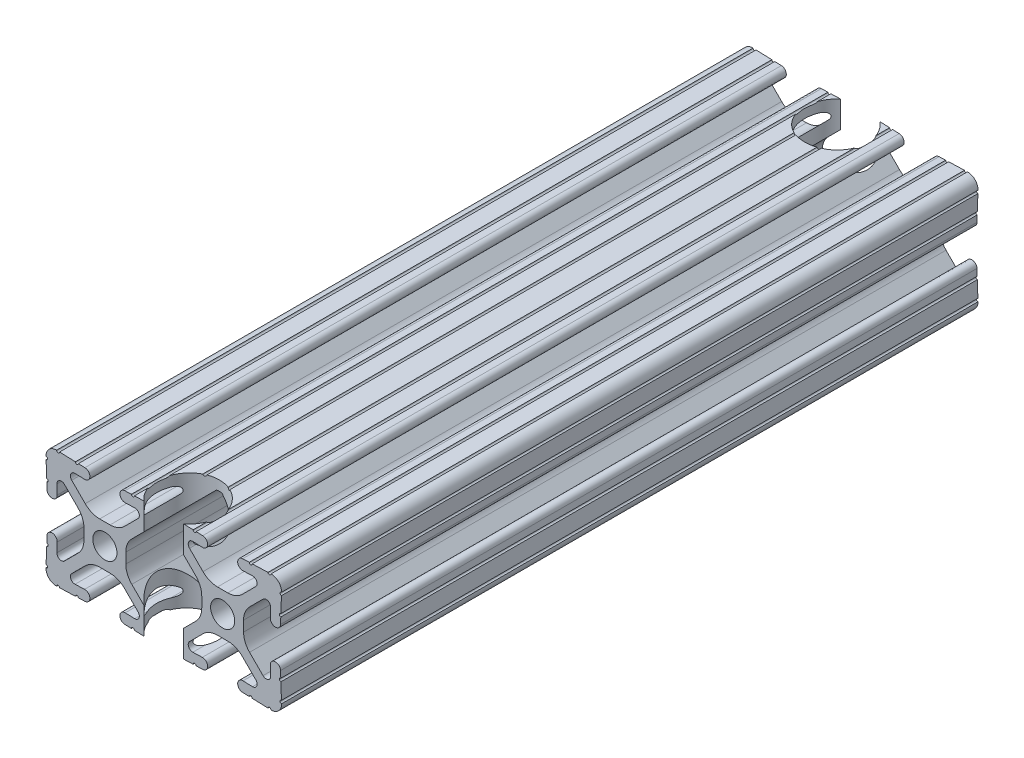
from build123d import *

# Parameters (mm, degrees)
SKETCH3_R               = 2.6035
EXTRUDE1_DEPTH          = 190
SKETCH4_R               = 6.75
CUT_EXTRUDE2_DEPTH      = 196.439764678
CUT_EXTRUDE3_DEPTH      = 10
CUT_EXTRUDE3_DEPTH_BACK = 196.439764775
SKETCH5_W               = 83.151552851
SKETCH5_H               = 42.692432645
CUT_EXTRUDE4_DEPTH      = 176.913968039
CUT_EXTRUDE4_DEPTH_BACK = 176.913968039
SKETCH6_W               = 68.118396993
SKETCH6_H               = 41.090203397


with BuildPart() as part:
    # Sketch3 → Extrude1 (new body)
    with BuildSketch(Plane.XY):
        with BuildLine():
            Line((-1.115277175, 4.5085), (1.115277175, 4.5085))
            ThreePointArc((1.115277175, 4.5085), (2.806584872, 4.844922018), (4.240406305, 5.80297087))
            Line((4.240406305, 5.80297087), (7.148423664, 8.710988229))
            ThreePointArc((7.148423664, 8.710988229), (7.349906316, 9.772227925), (6.436353897, 10.348636575))
            Line((6.436353897, 10.348636575), (4.381960454, 10.276895575))
            ThreePointArc((4.381960454, 10.276895575), (3.239173075, 11.342562046), (4.304839546, 12.485349424))
            Line((4.304839546, 12.485349424), (5.728246175, 12.535055879))
            ThreePointArc((5.728246175, 12.535055879), (6.054756855, 12.230579745), (6.35923299, 12.557090424))
            Line((6.35923299, 12.557090424), (9.782092278, 12.676619304))
            ThreePointArc((9.782092278, 12.676619304), (10.108602958, 12.37214317), (10.413079092, 12.69865385))
            Line((10.413079092, 12.69865385), (14.986920908, 12.69865385))
            ThreePointArc((14.986920908, 12.69865385), (15.291397042, 12.37214317), (15.617907722, 12.676619304))
            Line((15.617907722, 12.676619304), (19.04076701, 12.557090424))
            ThreePointArc((19.04076701, 12.557090424), (19.345243145, 12.230579745), (19.671753825, 12.535055879))
            Line((19.671753825, 12.535055879), (21.095160454, 12.485349424))
            ThreePointArc((21.095160454, 12.485349424), (22.160826925, 11.342562046), (21.018039546, 10.276895575))
            Line((21.018039546, 10.276895575), (18.963646103, 10.348636575))
            ThreePointArc((18.963646103, 10.348636575), (18.050093684, 9.772227925), (18.251576336, 8.710988229))
            Line((18.251576336, 8.710988229), (21.159593695, 5.80297087))
            ThreePointArc((21.159593695, 5.80297087), (22.593415128, 4.844922018), (24.284722825, 4.5085))
            Line((24.284722825, 4.5085), (26.515277175, 4.5085))
            ThreePointArc((26.515277175, 4.5085), (28.206584872, 4.844922018), (29.640406305, 5.80297087))
            Line((29.640406305, 5.80297087), (32.548423664, 8.710988229))
            ThreePointArc((32.548423664, 8.710988229), (32.749906316, 9.772227925), (31.836353897, 10.348636575))
            Line((31.836353897, 10.348636575), (29.781960454, 10.276895575))
            ThreePointArc((29.781960454, 10.276895575), (28.639173075, 11.342562046), (29.704839546, 12.485349424))
            Line((29.704839546, 12.485349424), (31.128246175, 12.535055879))
            ThreePointArc((31.128246175, 12.535055879), (31.454756855, 12.230579745), (31.75923299, 12.557090424))
            Line((31.75923299, 12.557090424), (35.182092278, 12.676619304))
            ThreePointArc((35.182092278, 12.676619304), (35.508602958, 12.37214317), (35.813079092, 12.69865385))
            ThreePointArc((35.813079092, 12.69865385), (37.452764565, 12.052764565), (38.09865385, 10.413079092))
            ThreePointArc((38.09865385, 10.413079092), (37.77214317, 10.108602958), (38.076619304, 9.782092278))
            Line((38.076619304, 9.782092278), (37.957090424, 6.35923299))
            ThreePointArc((37.957090424, 6.35923299), (37.630579745, 6.054756855), (37.935055879, 5.728246175))
            Line((37.935055879, 5.728246175), (37.885349424, 4.304839546))
            ThreePointArc((37.885349424, 4.304839546), (36.742562046, 3.239173075), (35.676895575, 4.381960454))
            Line((35.676895575, 4.381960454), (35.748636575, 6.436353897))
            ThreePointArc((35.748636575, 6.436353897), (35.172227925, 7.349906316), (34.110988229, 7.148423664))
            Line((34.110988229, 7.148423664), (31.202970856, 4.240406291))
            ThreePointArc((31.202970856, 4.240406291), (30.244922014, 2.806584863), (29.9085, 1.115277175))
            Line((29.9085, 1.115277175), (29.9085, -1.115277175))
            ThreePointArc((29.9085, -1.115277175), (30.244922014, -2.806584863), (31.202970856, -4.240406291))
            Line((31.202970856, -4.240406291), (34.110988229, -7.148423664))
            ThreePointArc((34.110988229, -7.148423664), (35.172227925, -7.349906316), (35.748636575, -6.436353897))
            Line((35.748636575, -6.436353897), (35.676895575, -4.381960454))
            ThreePointArc((35.676895575, -4.381960454), (36.742562046, -3.239173075), (37.885349424, -4.304839546))
            Line((37.885349424, -4.304839546), (37.935055879, -5.728246175))
            ThreePointArc((37.935055879, -5.728246175), (37.630579745, -6.054756855), (37.957090424, -6.35923299))
            Line((37.957090424, -6.35923299), (38.076619304, -9.782092278))
            ThreePointArc((38.076619304, -9.782092278), (37.77214317, -10.108602958), (38.09865385, -10.413079092))
            ThreePointArc((38.09865385, -10.413079092), (37.452764565, -12.052764565), (35.813079092, -12.69865385))
            ThreePointArc((35.813079092, -12.69865385), (35.508602958, -12.37214317), (35.182092278, -12.676619304))
            Line((35.182092278, -12.676619304), (31.75923299, -12.557090424))
            ThreePointArc((31.75923299, -12.557090424), (31.454756855, -12.230579745), (31.128246175, -12.535055879))
            Line((31.128246175, -12.535055879), (29.704839546, -12.485349424))
            ThreePointArc((29.704839546, -12.485349424), (28.639173075, -11.342562046), (29.781960454, -10.276895575))
            Line((29.781960454, -10.276895575), (31.836353897, -10.348636575))
            ThreePointArc((31.836353897, -10.348636575), (32.749906316, -9.772227925), (32.548423664, -8.710988229))
            Line((32.548423664, -8.710988229), (29.640406305, -5.80297087))
            ThreePointArc((29.640406305, -5.80297087), (28.206584872, -4.844922018), (26.515277175, -4.5085))
            Line((26.515277175, -4.5085), (24.284722825, -4.5085))
            ThreePointArc((24.284722825, -4.5085), (22.593415128, -4.844922018), (21.159593695, -5.80297087))
            Line((21.159593695, -5.80297087), (18.251576336, -8.710988229))
            ThreePointArc((18.251576336, -8.710988229), (18.050093684, -9.772227925), (18.963646103, -10.348636575))
            Line((18.963646103, -10.348636575), (21.018039546, -10.276895575))
            ThreePointArc((21.018039546, -10.276895575), (22.160826925, -11.342562046), (21.095160454, -12.485349424))
            Line((21.095160454, -12.485349424), (19.671753825, -12.535055879))
            ThreePointArc((19.671753825, -12.535055879), (19.345243145, -12.230579745), (19.04076701, -12.557090424))
            Line((19.04076701, -12.557090424), (15.617907722, -12.676619304))
            ThreePointArc((15.617907722, -12.676619304), (15.291397042, -12.37214317), (14.986920908, -12.69865385))
            Line((14.986920908, -12.69865385), (10.413079092, -12.69865385))
            ThreePointArc((10.413079092, -12.69865385), (10.108602958, -12.37214317), (9.782092278, -12.676619304))
            Line((9.782092278, -12.676619304), (6.35923299, -12.557090424))
            ThreePointArc((6.35923299, -12.557090424), (6.054756855, -12.230579745), (5.728246175, -12.535055879))
            Line((5.728246175, -12.535055879), (4.304839546, -12.485349424))
            ThreePointArc((4.304839546, -12.485349424), (3.239173075, -11.342562046), (4.381960454, -10.276895575))
            Line((4.381960454, -10.276895575), (6.436353897, -10.348636575))
            ThreePointArc((6.436353897, -10.348636575), (7.349906316, -9.772227925), (7.148423664, -8.710988229))
            Line((7.148423664, -8.710988229), (4.240406305, -5.80297087))
            ThreePointArc((4.240406305, -5.80297087), (2.806584872, -4.844922018), (1.115277175, -4.5085))
            Line((1.115277175, -4.5085), (-1.115277175, -4.5085))
            ThreePointArc((-1.115277175, -4.5085), (-2.806584872, -4.844922018), (-4.240406305, -5.80297087))
            Line((-4.240406305, -5.80297087), (-7.148423664, -8.710988229))
            ThreePointArc((-7.148423664, -8.710988229), (-7.349906316, -9.772227925), (-6.436353897, -10.348636575))
            Line((-6.436353897, -10.348636575), (-4.381960454, -10.276895575))
            ThreePointArc((-4.381960454, -10.276895575), (-3.239173075, -11.342562046), (-4.304839546, -12.485349424))
            Line((-4.304839546, -12.485349424), (-5.728246175, -12.535055879))
            ThreePointArc((-5.728246175, -12.535055879), (-6.054756855, -12.230579745), (-6.35923299, -12.557090424))
            Line((-6.35923299, -12.557090424), (-9.782092278, -12.676619304))
            ThreePointArc((-9.782092278, -12.676619304), (-10.108602958, -12.37214317), (-10.413079092, -12.69865385))
            ThreePointArc((-10.413079092, -12.69865385), (-12.052764565, -12.052764565), (-12.69865385, -10.413079092))
            ThreePointArc((-12.69865385, -10.413079092), (-12.37214317, -10.108602958), (-12.676619304, -9.782092278))
            Line((-12.676619304, -9.782092278), (-12.557090424, -6.35923299))
            ThreePointArc((-12.557090424, -6.35923299), (-12.230579745, -6.054756855), (-12.535055879, -5.728246175))
            Line((-12.535055879, -5.728246175), (-12.485349424, -4.304839546))
            ThreePointArc((-12.485349424, -4.304839546), (-11.342562046, -3.239173075), (-10.276895575, -4.381960454))
            Line((-10.276895575, -4.381960454), (-10.348636575, -6.436353897))
            ThreePointArc((-10.348636575, -6.436353897), (-9.772227925, -7.349906316), (-8.710988229, -7.148423664))
            Line((-8.710988229, -7.148423664), (-5.802970856, -4.240406291))
            ThreePointArc((-5.802970856, -4.240406291), (-4.844922014, -2.806584863), (-4.5085, -1.115277175))
            Line((-4.5085, -1.115277175), (-4.5085, 1.115277175))
            ThreePointArc((-4.5085, 1.115277175), (-4.844922014, 2.806584863), (-5.802970856, 4.240406291))
            Line((-5.802970856, 4.240406291), (-8.710988229, 7.148423664))
            ThreePointArc((-8.710988229, 7.148423664), (-9.772227925, 7.349906316), (-10.348636575, 6.436353897))
            Line((-10.348636575, 6.436353897), (-10.276895575, 4.381960454))
            ThreePointArc((-10.276895575, 4.381960454), (-11.342562046, 3.239173075), (-12.485349424, 4.304839546))
            Line((-12.485349424, 4.304839546), (-12.535055879, 5.728246175))
            ThreePointArc((-12.535055879, 5.728246175), (-12.230579745, 6.054756855), (-12.557090424, 6.35923299))
            Line((-12.557090424, 6.35923299), (-12.676619304, 9.782092278))
            ThreePointArc((-12.676619304, 9.782092278), (-12.37214317, 10.108602958), (-12.69865385, 10.413079092))
            ThreePointArc((-12.69865385, 10.413079092), (-12.052764565, 12.052764565), (-10.413079092, 12.69865385))
            ThreePointArc((-10.413079092, 12.69865385), (-10.108602958, 12.37214317), (-9.782092278, 12.676619304))
            Line((-9.782092278, 12.676619304), (-6.35923299, 12.557090424))
            ThreePointArc((-6.35923299, 12.557090424), (-6.054756855, 12.230579745), (-5.728246175, 12.535055879))
            Line((-5.728246175, 12.535055879), (-4.304839546, 12.485349424))
            ThreePointArc((-4.304839546, 12.485349424), (-3.239173075, 11.342562046), (-4.381960454, 10.276895575))
            Line((-4.381960454, 10.276895575), (-6.436353897, 10.348636575))
            ThreePointArc((-6.436353897, 10.348636575), (-7.349906316, 9.772227925), (-7.148423664, 8.710988229))
            Line((-7.148423664, 8.710988229), (-4.240406305, 5.80297087))
            ThreePointArc((-4.240406305, 5.80297087), (-2.806584872, 4.844922018), (-1.115277175, 4.5085))
        make_face()
        with Locations((25.4, 0)):
            Circle(SKETCH3_R, mode=Mode.SUBTRACT)
        Circle(SKETCH3_R, mode=Mode.SUBTRACT)
        with BuildLine():
            Line((5.802970856, 4.240406291), (12.109304956, 10.546740391))
            Line((12.109304956, 10.546740391), (12.7, 10.567367916))
            Line((12.7, 10.567367916), (13.290695044, 10.546740391))
            Line((13.290695044, 10.546740391), (19.597029144, 4.240406291))
            ThreePointArc((19.597029144, 4.240406291), (20.555077986, 2.806584863), (20.8915, 1.115277175))
            Line((20.8915, 1.115277175), (20.8915, -1.115277175))
            ThreePointArc((20.8915, -1.115277175), (20.555077986, -2.806584863), (19.597029144, -4.240406291))
            Line((19.597029144, -4.240406291), (13.290695044, -10.546740391))
            Line((13.290695044, -10.546740391), (12.7, -10.567367916))
            Line((12.7, -10.567367916), (12.109304956, -10.546740391))
            Line((12.109304956, -10.546740391), (5.802970856, -4.240406291))
            ThreePointArc((5.802970856, -4.240406291), (4.844922014, -2.806584863), (4.5085, -1.115277175))
            Line((4.5085, -1.115277175), (4.5085, 1.115277175))
            ThreePointArc((4.5085, 1.115277175), (4.844922014, 2.806584863), (5.802970856, 4.240406291))
        make_face(mode=Mode.SUBTRACT)
    extrude(amount=EXTRUDE1_DEPTH)

    # Sketch4 → Cut-Extrude2 (cut, through all)
    with BuildSketch(Plane(origin=(0, 12.69865385, 0), x_dir=(1, 0, 0), z_dir=(0, 1, 0))):
        with Locations((12.7, -164.6)):
            Circle(SKETCH4_R)
        with Locations((12.7, -24.9)):
            Circle(SKETCH4_R)
    extrude(amount=-CUT_EXTRUDE2_DEPTH, mode=Mode.SUBTRACT)

    # Sketch5 → Cut-Extrude3 (cut, two sides: drawn at the far end of the back side and taken through both)
    with BuildSketch(Plane.XZ.offset(12.69865385).offset(-CUT_EXTRUDE3_DEPTH_BACK)):
        with Locations((14.845499659, 191.196216323)):
            Rectangle(SKETCH5_W, SKETCH5_H)
    extrude(amount=CUT_EXTRUDE3_DEPTH + CUT_EXTRUDE3_DEPTH_BACK, mode=Mode.SUBTRACT)

    # Sketch6 → Cut-Extrude4 (cut, two sides: drawn at the far end of the back side and taken through both)
    with BuildSketch(Plane(origin=(0, 12.69865385, 0), x_dir=(1, 0, 0), z_dir=(0, 1, 0)).offset(-CUT_EXTRUDE4_DEPTH_BACK)):
        with Locations((11.595610499, 0.895101698)):
            Rectangle(SKETCH6_W, SKETCH6_H)
    extrude(amount=CUT_EXTRUDE4_DEPTH + CUT_EXTRUDE4_DEPTH_BACK, mode=Mode.SUBTRACT)


solid = part.part
